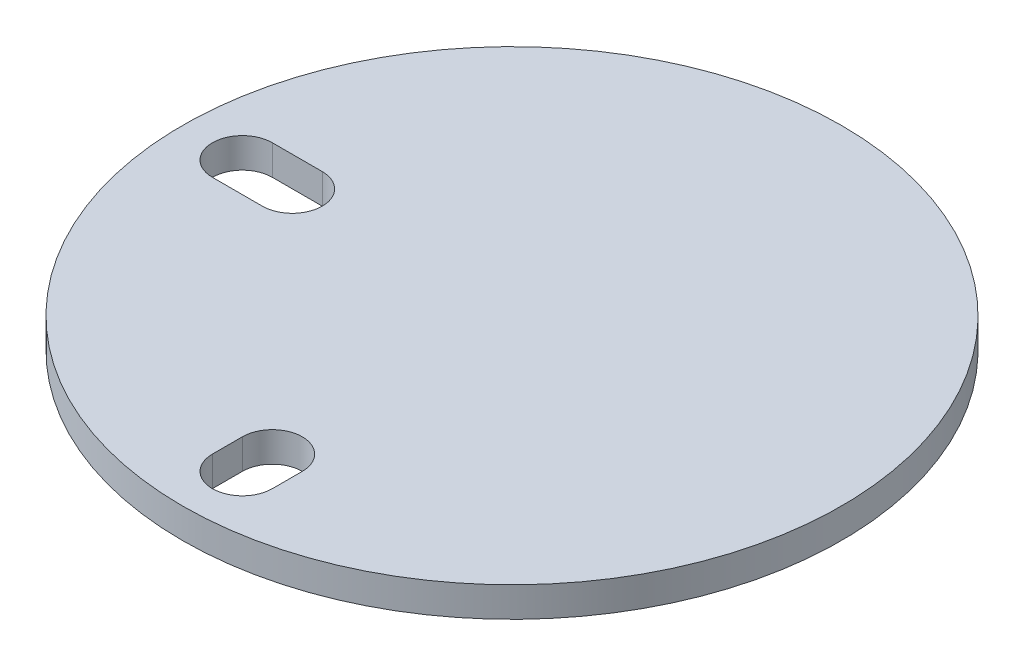
from build123d import *

# Parameters (mm, degrees)
SKETCH1_R           = 33
BOSS_EXTRUDE1_DEPTH = 3


with BuildPart() as part:
    # Sketch1 → Boss-Extrude1 (new body)
    with BuildSketch(Plane(origin=(0, 0, 0), x_dir=(1, 0, 0), z_dir=(0, 1, 0))):
        Circle(SKETCH1_R)
        with BuildLine():
            Line((-27, 3), (-22, 3))
            ThreePointArc((-22, 3), (-19.000055351, 0.018223725), (-21.963553222, -2.999778597))
            Line((-21.963553222, -2.999778597), (-27, -3))
            ThreePointArc((-27, -3), (-30, 0), (-27, 3))
        make_face(mode=Mode.SUBTRACT)
        with BuildLine():
            Line((-3, -27), (-3, -24))
            ThreePointArc((-3, -24), (0, -21), (3, -24))
            Line((3, -24), (3, -27))
            ThreePointArc((3, -27), (0, -30), (-3, -27))
        make_face(mode=Mode.SUBTRACT)
    extrude(amount=BOSS_EXTRUDE1_DEPTH)


solid = part.part
